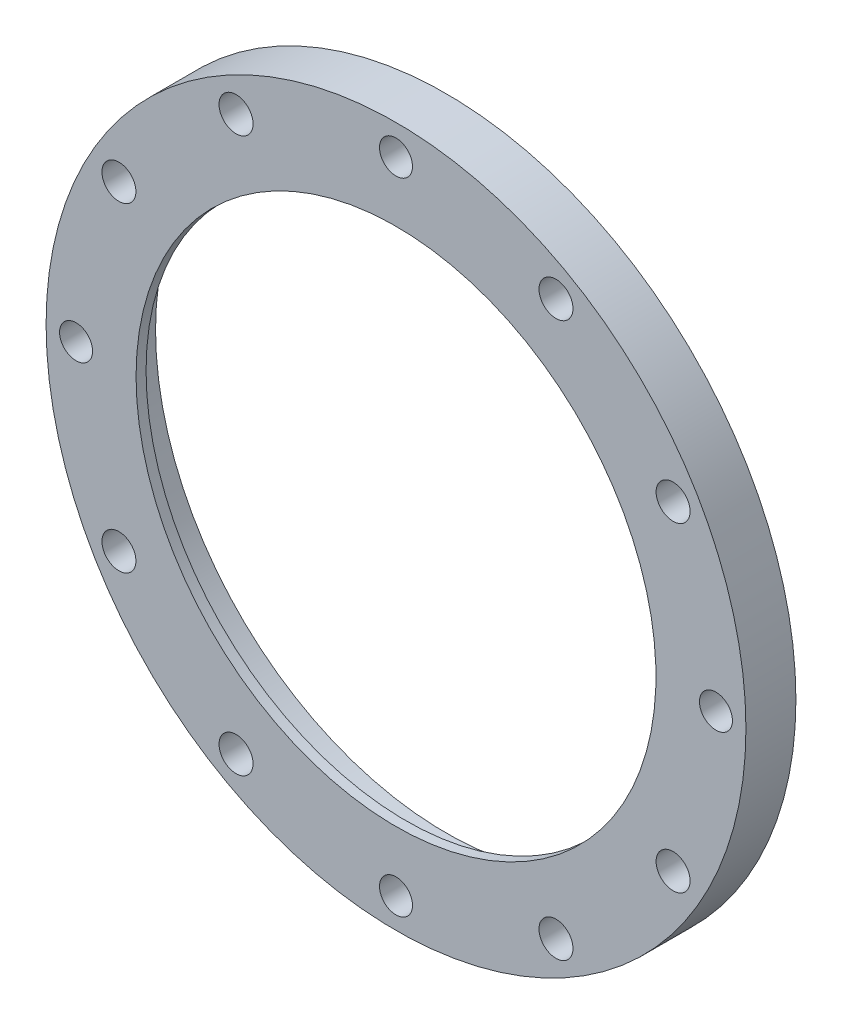
from build123d import *

# Parameters (mm, degrees)
SKETCH_1_W                = 35
SKETCH_1_H                = 5
HOLE_WIZARD_1_D           = 3.4
HOLE_WIZARD_1_DEPTH       = 5
HOLE_WIZARD_2_D           = 52
HOLE_WIZARD_2_DEPTH       = 5
HOLE_WIZARD_2_CBORE_D     = 58.1
HOLE_WIZARD_2_CBORE_DEPTH = 4
SKETCH_9_R                = 1.65
CUT_EXTRUDE_1_DEPTH       = 10


with BuildPart() as part:
    # 草图1 → 旋转1 (revolve)
    with BuildSketch(Plane(origin=(0, 0, 0), x_dir=(1, 0, 0), z_dir=(0, 1, 0))):
        with Locations((17.5, 2.5)):
            Rectangle(SKETCH_1_W, SKETCH_1_H)
    revolve(axis=Axis((0, 0, -5), (0, 0, 1)))

    # 孔1
    with Locations(Plane(origin=(0, 0, -5), x_dir=(-1, 0, 0), z_dir=(0, 0, -1))):
        with Locations((16, -27.712812921), (-16, -27.712812921), (-27.712812921, -16), (-27.712812921, 16), (-16, 27.712812921), (16, 27.712812921), (27.712812921, 16), (27.712812921, -16)):
            Hole(HOLE_WIZARD_1_D / 2, depth=HOLE_WIZARD_1_DEPTH)

    # 孔2
    with Locations(Plane(origin=(0, 0, -5), x_dir=(-1, 0, 0), z_dir=(0, 0, -1))):
        with Locations((0, 0)):
            CounterBoreHole(HOLE_WIZARD_2_D / 2, HOLE_WIZARD_2_CBORE_D / 2, HOLE_WIZARD_2_CBORE_DEPTH, depth=HOLE_WIZARD_2_DEPTH)

    # 草图9 → 切除-拉伸1 (cut)
    with BuildSketch(Plane(origin=(0, 0, -5), x_dir=(-1, 0, 0), z_dir=(0, 0, -1))):
        with Locations((32, 0)):
            Circle(SKETCH_9_R)
        with Locations((0, -32)):
            Circle(SKETCH_9_R)
        with Locations((-32, 0)):
            Circle(SKETCH_9_R)
        with Locations((0, 32)):
            Circle(SKETCH_9_R)
    extrude(amount=-CUT_EXTRUDE_1_DEPTH, mode=Mode.SUBTRACT)


solid = part.part
